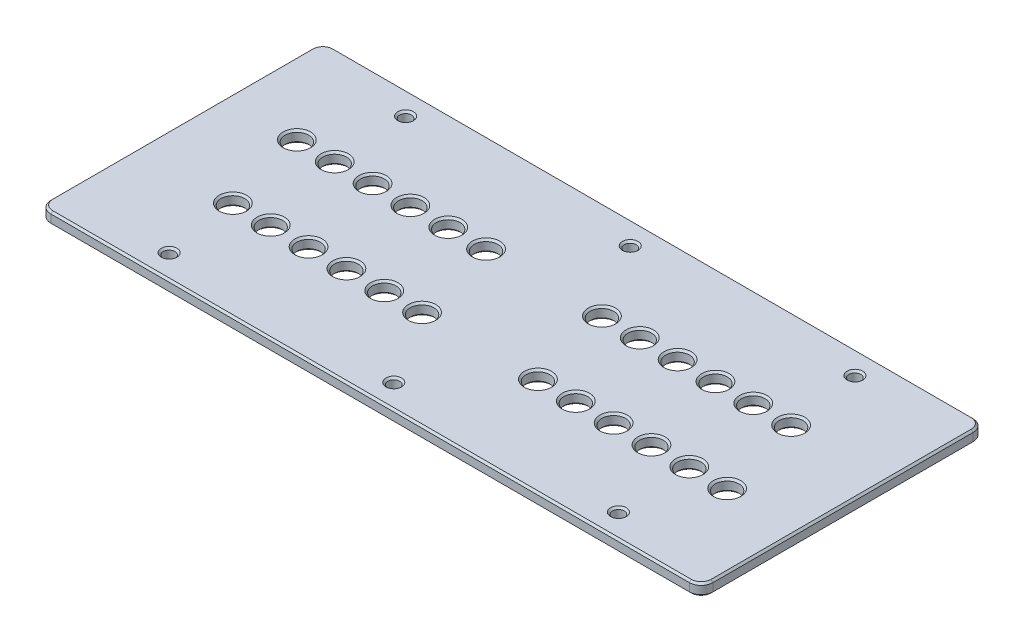
from build123d import *

# Parameters (mm, degrees)
SKETCH1_W                    = 177.8
SKETCH1_H                    = 76.2
BOSS_EXTRUDE1_DEPTH          = 1.5875
F_1_8_0_125_DIAMETER_HOLE1_D = 3.175
F_1_4_0_25_DIAMETER_HOLE1_D  = 6.35
FILLET1_R                    = 3.175
CHAMFER1_SIZE                = 0.508


with BuildPart() as part:
    # Sketch1 → Boss-Extrude1 (new body, symmetric)
    with BuildSketch(Plane(origin=(0, 0, 0), x_dir=(1, 0, 0), z_dir=(0, 1, 0))):
        Rectangle(SKETCH1_W, SKETCH1_H)
    extrude(amount=BOSS_EXTRUDE1_DEPTH, both=True)

    # 1/8 (0.125) Diameter Hole1 (through all)
    with Locations(Plane(origin=(0, 1.5875, 0), x_dir=(1, 0, 0), z_dir=(0, 1, 0))):
        with Locations((-60.325, 31.75), (0, 31.75), (60.325, 31.75), (60.325, -31.75), (0, -31.75), (-60.325, -31.75)):
            Hole(F_1_8_0_125_DIAMETER_HOLE1_D / 2)

    # 1/4 (0.25) Diameter Hole1 (through all)
    with Locations(Plane(origin=(0, 1.5875, 0), x_dir=(1, 0, 0), z_dir=(0, 1, 0))):
        with Locations((-63.28664, -11.66114), (-53.12664, -11.66114), (-42.96664, -11.66114), (-32.80664, -11.66114), (-22.64664, -11.66114), (-12.48664, -11.66114), (18.62836, -11.66114), (28.78836, -11.66114), (38.94836, -11.66114), (49.10836, -11.66114), (59.26836, -11.66114), (69.42836, -11.66114), (-69.42836, 11.66114), (-59.26836, 11.66114), (-49.10836, 11.66114), (-38.94836, 11.66114), (-28.78836, 11.66114), (-18.62836, 11.66114), (12.48664, 11.66114), (22.64664, 11.66114), (32.80664, 11.66114), (42.96664, 11.66114), (53.12664, 11.66114), (63.28664, 11.66114)):
            Hole(F_1_4_0_25_DIAMETER_HOLE1_D / 2)

    # Fillet1
    fillet1_edges = [part.edges().sort_by_distance(p)[0] for p in [
        (-88.9, 0, 38.1),
        (88.9, 0, 38.1),
        (88.9, 0, -38.1),
        (-88.9, 0, -38.1),
    ]]
    fillet(fillet1_edges, radius=FILLET1_R)

    # Chamfer1
    chamfer1_edges = [part.edges().sort_by_distance(p)[0] for p in [
        (15.66164, 1.5875, -11.66114),
        (15.66164, -1.5875, -11.66114),
        (-15.45336, 1.5875, -11.66114),
        (-15.45336, -1.5875, -11.66114),
        (-25.61336, 1.5875, -11.66114),
        (-25.61336, -1.5875, -11.66114),
        (-35.77336, 1.5875, -11.66114),
        (-35.77336, -1.5875, -11.66114),
        (-45.93336, 1.5875, -11.66114),
        (-45.93336, -1.5875, -11.66114),
        (-56.09336, 1.5875, -11.66114),
        (-56.09336, -1.5875, -11.66114),
        (-66.25336, 1.5875, -11.66114),
        (-66.25336, -1.5875, -11.66114),
        (72.60336, 1.5875, 11.66114),
        (72.60336, -1.5875, 11.66114),
        (-58.7375, 1.5875, 31.75),
        (-58.7375, -1.5875, 31.75),
        (62.44336, 1.5875, 11.66114),
        (62.44336, -1.5875, 11.66114),
        (52.28336, 1.5875, 11.66114),
        (52.28336, -1.5875, 11.66114),
        (42.12336, 1.5875, 11.66114),
        (42.12336, -1.5875, 11.66114),
        (31.96336, 1.5875, 11.66114),
        (31.96336, -1.5875, 11.66114),
        (21.80336, 1.5875, 11.66114),
        (21.80336, -1.5875, 11.66114),
        (-9.31164, 1.5875, 11.66114),
        (-9.31164, -1.5875, 11.66114),
        (1.5875, 1.5875, 31.75),
        (1.5875, -1.5875, 31.75),
        (-19.47164, 1.5875, 11.66114),
        (-19.47164, -1.5875, 11.66114),
        (-29.63164, 1.5875, 11.66114),
        (-29.63164, -1.5875, 11.66114),
        (-39.79164, 1.5875, 11.66114),
        (-39.79164, -1.5875, 11.66114),
        (-49.95164, 1.5875, 11.66114),
        (-49.95164, -1.5875, 11.66114),
        (-60.11164, 1.5875, 11.66114),
        (-60.11164, -1.5875, 11.66114),
        (-88.9, -1.5875, 0),
        (-88.9, 1.5875, 0),
        (0, -1.5875, -38.1),
        (88.9, -1.5875, 0),
        (0, -1.5875, 38.1),
        (61.9125, 1.5875, 31.75),
        (-87.97006403, -1.5875, 37.17006403),
        (87.97006403, -1.5875, 37.17006403),
        (61.9125, -1.5875, 31.75),
        (87.97006403, -1.5875, -37.17006403),
        (-87.97006403, -1.5875, -37.17006403),
        (0, 1.5875, -38.1),
        (0, 1.5875, 38.1),
        (88.9, 1.5875, 0),
        (-87.97006403, 1.5875, 37.17006403),
        (87.97006403, 1.5875, 37.17006403),
        (87.97006403, 1.5875, -37.17006403),
        (-87.97006403, 1.5875, -37.17006403),
        (61.9125, 1.5875, -31.75),
        (61.9125, -1.5875, -31.75),
        (1.5875, 1.5875, -31.75),
        (1.5875, -1.5875, -31.75),
        (-58.7375, 1.5875, -31.75),
        (-58.7375, -1.5875, -31.75),
        (56.30164, 1.5875, -11.66114),
        (56.30164, -1.5875, -11.66114),
        (66.46164, 1.5875, -11.66114),
        (66.46164, -1.5875, -11.66114),
        (46.14164, 1.5875, -11.66114),
        (46.14164, -1.5875, -11.66114),
        (35.98164, 1.5875, -11.66114),
        (35.98164, -1.5875, -11.66114),
        (25.82164, 1.5875, -11.66114),
        (25.82164, -1.5875, -11.66114),
    ]]
    chamfer(chamfer1_edges, length=CHAMFER1_SIZE)


solid = part.part
